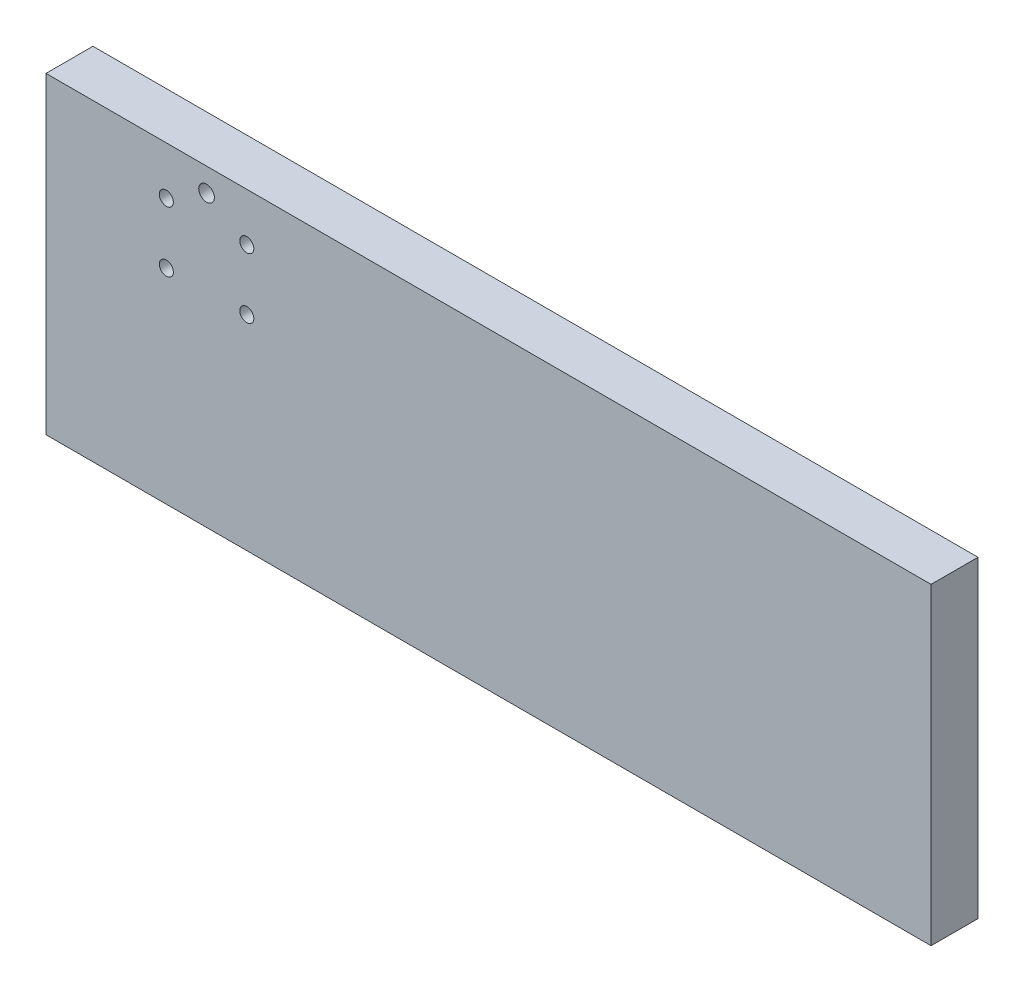
from build123d import *

# Parameters (mm, degrees)
SKETCH1_W           = 359.156
SKETCH1_H           = 127
BOSS_EXTRUDE1_DEPTH = 19.05
CUT_EXTRUDE1_REACH  = 21.05
SKETCH2_R           = 2.85115
CUT_EXTRUDE2_START  = -19.05
SKETCH3_R           = 3.175
CUT_EXTRUDE2_DEPTH  = 6.35


with BuildPart() as part:
    # Sketch1 → Boss-Extrude1 (new body)
    with BuildSketch(Plane.XY):
        with Locations((179.578, 63.5)):
            Rectangle(SKETCH1_W, SKETCH1_H)
    extrude(amount=BOSS_EXTRUDE1_DEPTH)

    # Sketch2 → Cut-Extrude1 (cut, up to next)
    with BuildSketch(Plane.XY.offset(19.05), mode=Mode.PRIVATE) as cut_extrude1_sk1:
        with Locations((48.82515, 82.96275)):
            Circle(SKETCH2_R)
    cut_extrude1_tool1 = extrude(cut_extrude1_sk1.sketch, amount=-CUT_EXTRUDE1_REACH, mode=Mode.PRIVATE) & part.part
    add(cut_extrude1_tool1.solids().sort_by_distance((48.82515, 82.96275, 19.05))[0], mode=Mode.SUBTRACT)
    # Sketch2 → Cut-Extrude1 (cut, up to next)
    with BuildSketch(Plane.XY.offset(19.05), mode=Mode.PRIVATE) as cut_extrude1_sk2:
        with Locations((48.82515, 107.53725)):
            Circle(SKETCH2_R)
    cut_extrude1_tool2 = extrude(cut_extrude1_sk2.sketch, amount=-CUT_EXTRUDE1_REACH, mode=Mode.PRIVATE) & part.part
    add(cut_extrude1_tool2.solids().sort_by_distance((48.82515, 107.53725, 19.05))[0], mode=Mode.SUBTRACT)
    # Sketch2 → Cut-Extrude1 (cut, up to next)
    with BuildSketch(Plane.XY.offset(19.05), mode=Mode.PRIVATE) as cut_extrude1_sk3:
        with Locations((81.47685, 107.53725)):
            Circle(SKETCH2_R)
    cut_extrude1_tool3 = extrude(cut_extrude1_sk3.sketch, amount=-CUT_EXTRUDE1_REACH, mode=Mode.PRIVATE) & part.part
    add(cut_extrude1_tool3.solids().sort_by_distance((81.47685, 107.53725, 19.05))[0], mode=Mode.SUBTRACT)
    # Sketch2 → Cut-Extrude1 (cut, up to next)
    with BuildSketch(Plane.XY.offset(19.05), mode=Mode.PRIVATE) as cut_extrude1_sk4:
        with Locations((81.47685, 82.96275)):
            Circle(SKETCH2_R)
    cut_extrude1_tool4 = extrude(cut_extrude1_sk4.sketch, amount=-CUT_EXTRUDE1_REACH, mode=Mode.PRIVATE) & part.part
    add(cut_extrude1_tool4.solids().sort_by_distance((81.47685, 82.96275, 19.05))[0], mode=Mode.SUBTRACT)

    # Sketch3 → Cut-Extrude2 (cut)
    with BuildSketch(Plane(origin=(0, 0, 0), x_dir=(-1, 0, 0), z_dir=(0, 0, -1)).offset(CUT_EXTRUDE2_START)):
        with Locations((-65.151, 117.475)):
            Circle(SKETCH3_R)
    extrude(amount=CUT_EXTRUDE2_DEPTH, mode=Mode.SUBTRACT)


solid = part.part
